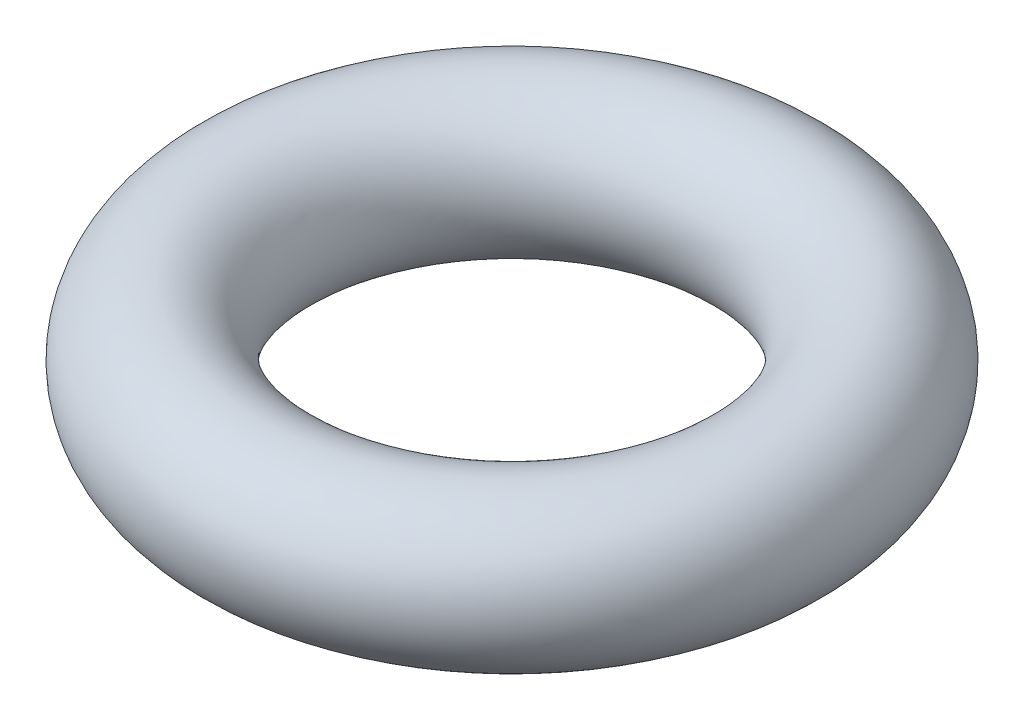
from build123d import *

# Parameters (mm, degrees)
SKETCH2_R = 1.651


with BuildPart() as part:
    # Sweep1: sweep along a path in Sketch1
    with BuildLine(Plane(origin=(0, 0, 0), x_dir=(1, 0, 0), z_dir=(0, 1, 0))) as sweep1_path:
        CenterArc((0, 0), 3.937, 0, 360)
    # Sketch2 → Sweep1 (sweep)
    with BuildSketch(Plane.XY):
        with Locations((-5.588, 0)):
            Circle(SKETCH2_R)
    sweep(path=sweep1_path.line)


solid = part.part
